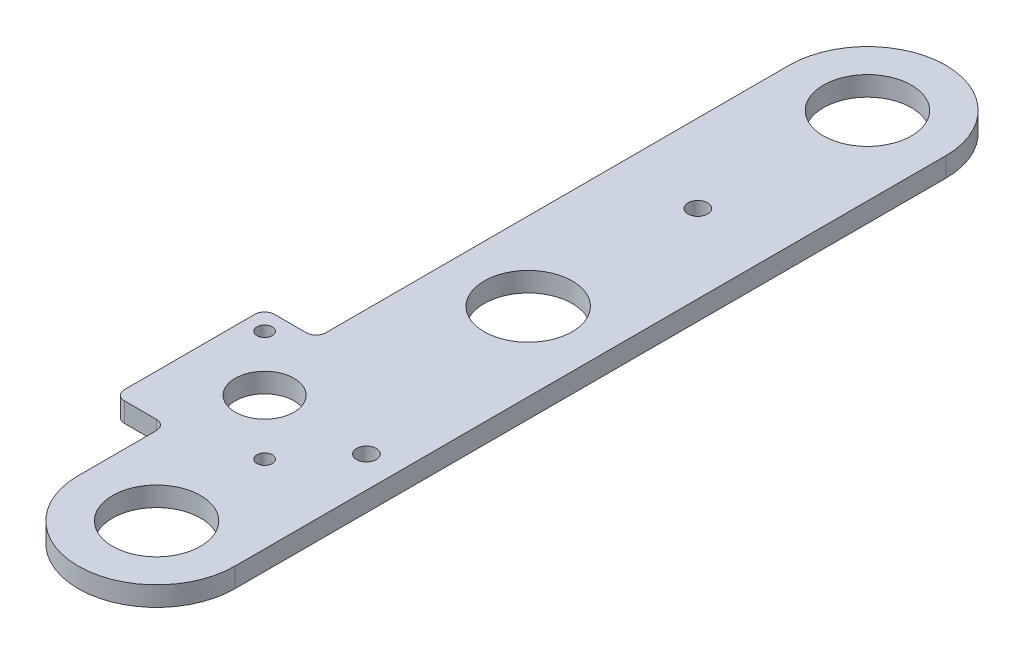
from build123d import *

# Parameters (mm, degrees)
SKETCH3_R           = 14.2748
SKETCH3_R_2         = 9.525
SKETCH3_R_3         = 2.4892
SKETCH3_R_4         = 3.175
BOSS_EXTRUDE1_DEPTH = 6.35


with BuildPart() as part:
    # Sketch3 → Boss-Extrude1 (new body)
    with BuildSketch(Plane(origin=(0, 0, 0), x_dir=(1, 0, 0), z_dir=(0, 1, 0))):
        with BuildLine():
            Line((-249.735512242, 346.01236887), (-239.395, 346.01236887))
            ThreePointArc((-239.395, 346.01236887), (-237.14993597, 345.0824329), (-236.22, 342.83736887))
            Line((-236.22, 342.83736887), (-236.22, 317.5))
            ThreePointArc((-236.22, 317.5), (-210.82, 292.1), (-185.42, 317.5))
            Line((-185.42, 317.5), (-185.42, 548.034576396))
            ThreePointArc((-185.42, 548.034576396), (-210.82, 573.434576396), (-236.22, 548.034576396))
            Line((-236.22, 548.034576396), (-236.22, 397.808393354))
            ThreePointArc((-236.22, 397.808393354), (-237.14993597, 395.563329324), (-239.395, 394.633393354))
            Line((-239.395, 394.633393354), (-249.735512242, 394.633393354))
            ThreePointArc((-249.735512242, 394.633393354), (-251.980576272, 393.703457384), (-252.910512242, 391.458393354))
            Line((-252.910512242, 391.458393354), (-252.910512242, 349.18736887))
            ThreePointArc((-252.910512242, 349.18736887), (-251.980576272, 346.942304839), (-249.735512242, 346.01236887))
        make_face()
        with Locations((-210.82, 548.034576396)):
            Circle(SKETCH3_R, mode=Mode.SUBTRACT)
        with Locations((-210.82, 438.027176396)):
            Circle(SKETCH3_R, mode=Mode.SUBTRACT)
        with Locations((-210.82, 317.5)):
            Circle(SKETCH3_R, mode=Mode.SUBTRACT)
        with Locations((-228.6, 370.322881112)):
            Circle(SKETCH3_R_2, mode=Mode.SUBTRACT)
        with Locations((-246.560512242, 388.283393354)):
            Circle(SKETCH3_R_3, mode=Mode.SUBTRACT)
        with Locations((-210.639487758, 352.36236887)):
            Circle(SKETCH3_R_3, mode=Mode.SUBTRACT)
        with Locations((-210.82, 493.030876396)):
            Circle(SKETCH3_R_4, mode=Mode.SUBTRACT)
        with Locations((-195.58, 370.322881112)):
            Circle(SKETCH3_R_4, mode=Mode.SUBTRACT)
    extrude(amount=BOSS_EXTRUDE1_DEPTH)


solid = part.part
